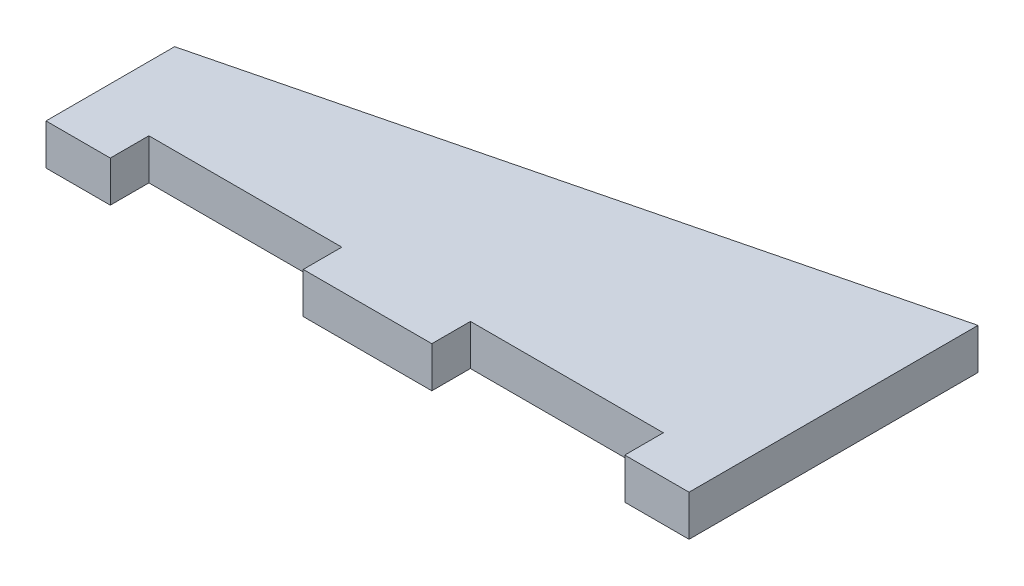
from build123d import *

# Parameters (mm, degrees)
BOSS_EXTRUDE1_DEPTH = 6.35


with BuildPart() as part:
    # Sketch1 → Boss-Extrude1 (new body)
    with BuildSketch(Plane(origin=(0, 0, 0), x_dir=(1, 0, 0), z_dir=(0, 1, 0))):
        Polygon((0, 0), (10, 0), (10, 6), (40, 6), (40, 0), (60, 0), (60, 6), (90, 6), (90, 0), (100, 0), (100, 44.932800284), (0, 20), align=None)
    extrude(amount=BOSS_EXTRUDE1_DEPTH)


solid = part.part
